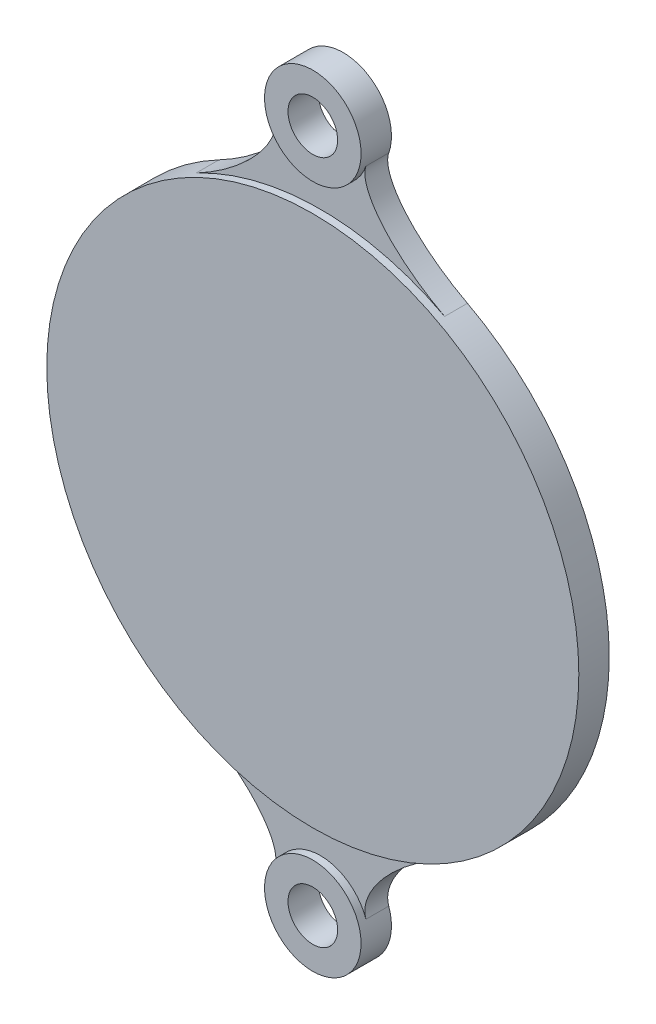
from build123d import *

# Parameters (mm, degrees)
SKETCH1_R           = 3.2639
BOSS_EXTRUDE1_DEPTH = 3
BOSS_EXTRUDE2_START = 1
SKETCH1_3_R         = 35
SKETCH1_3_R_2       = 6.35
SKETCH1_3_R_3       = 3.2639
BOSS_EXTRUDE2_DEPTH = 1
SKETCH1_4_W         = 6.5
SKETCH1_4_H         = 15
BOSS_EXTRUDE3_DEPTH = 6
FILLET1_R           = 2
CHAMFER1_SIZE       = 0.3


with BuildPart() as part:
    # Sketch1 → Boss-Extrude1 (new body)
    with BuildSketch(Plane.XY):
        with BuildLine():
            ThreePointArc((16.34412633, -30.949467435), (35, 0), (16.34412633, 30.949467435))
            add(Edge.make_bspline(
                [(5.995119548, 42.906906211), (4.99402394, 40.039529756), (9.395219997, 34.619120336), (16.34412633, 30.949467435)],
                knots=[0, 0, 0, 0, 1, 1, 1, 1], degree=3))
            ThreePointArc((5.995119548, 42.906906211), (0, 51.35), (-5.995119548, 42.906906211))
            add(Edge.make_bspline(
                [(-5.995119548, 42.906906211), (-4.99402394, 40.039529756), (-9.395219997, 34.619120336), (-16.34412633, 30.949467435)],
                knots=[0, 0, 0, 0, 1, 1, 1, 1], degree=3))
            ThreePointArc((-16.34412633, 30.949467435), (-35, 0), (-16.34412633, -30.949467435))
            add(Edge.make_bspline(
                [(-5.995119548, -42.906906211), (-4.99402394, -40.039529756), (-9.395219997, -34.619120336), (-16.34412633, -30.949467435)],
                knots=[0, 0, 0, 0, 1, 1, 1, 1], degree=3))
            ThreePointArc((-5.995119548, -42.906906211), (0, -51.35), (5.995119548, -42.906906211))
            add(Edge.make_bspline(
                [(5.995119548, -42.906906211), (4.99402394, -40.039529756), (9.395219997, -34.619120336), (16.34412633, -30.949467435)],
                knots=[0, 0, 0, 0, 1, 1, 1, 1], degree=3))
        make_face()
        with Locations((0, -45)):
            Circle(SKETCH1_R, mode=Mode.SUBTRACT)
        with Locations((0, 45)):
            Circle(SKETCH1_R, mode=Mode.SUBTRACT)
    extrude(amount=-BOSS_EXTRUDE1_DEPTH)

    # Sketch1_3 → Boss-Extrude2 (add)
    # profile 1 of 3: a face of its own
    with BuildSketch(Plane.XY.offset(BOSS_EXTRUDE2_START)):
        Circle(SKETCH1_3_R)
    # profile 2 of 3: a face of its own
    with BuildSketch(Plane.XY.offset(BOSS_EXTRUDE2_START)):
        with Locations((0, 45)):
            Circle(SKETCH1_3_R_2)
        with Locations((0, 45)):
            Circle(SKETCH1_3_R_3, mode=Mode.SUBTRACT)
    # profile 3 of 3: a face of its own
    with BuildSketch(Plane.XY.offset(BOSS_EXTRUDE2_START)):
        with Locations((0, -45)):
            Circle(SKETCH1_3_R_2)
        with Locations((0, -45)):
            Circle(SKETCH1_3_R_3, mode=Mode.SUBTRACT)
    extrude(amount=-BOSS_EXTRUDE2_DEPTH)

    # Sketch1_4 → Boss-Extrude3 (add)
    with BuildSketch(Plane.XY):
        with Locations((0, 20)):
            Rectangle(SKETCH1_4_W, SKETCH1_4_H)
        with Locations((0, -20)):
            Rectangle(SKETCH1_4_W, SKETCH1_4_H)
    extrude(amount=-BOSS_EXTRUDE3_DEPTH)

    # Fillet1
    fillet1_edges = [part.edges().sort_by_distance(p)[0] for p in [
        (-3.25, 27.5, -4.5),
        (3.25, 27.5, -4.5),
        (-3.25, 12.5, -4.5),
        (3.25, 12.5, -4.5),
        (-3.25, -12.5, -4.5),
        (3.25, -12.5, -4.5),
        (3.25, -27.5, -4.5),
        (-3.25, -27.5, -4.5),
    ]]
    fillet(fillet1_edges, radius=FILLET1_R)

    # Chamfer1
    chamfer1_edges = [part.edges().sort_by_distance(p)[0] for p in [
        (-3.25, 20, -6),
        (-2.664213562, 13.085786438, -6),
        (-2.664213562, 26.914213562, -6),
        (0, 12.5, -6),
        (0, 27.5, -6),
        (2.664213562, 13.085786438, -6),
        (2.664213562, 26.914213562, -6),
        (3.25, 20, -6),
        (-3.25, -20, -6),
        (-2.664213562, -13.085786438, -6),
        (-2.664213562, -26.914213562, -6),
        (0, -12.5, -6),
        (0, -27.5, -6),
        (2.664213562, -13.085786438, -6),
        (2.664213562, -26.914213562, -6),
        (3.25, -20, -6),
    ]]
    chamfer(chamfer1_edges, length=CHAMFER1_SIZE)


solid = part.part
